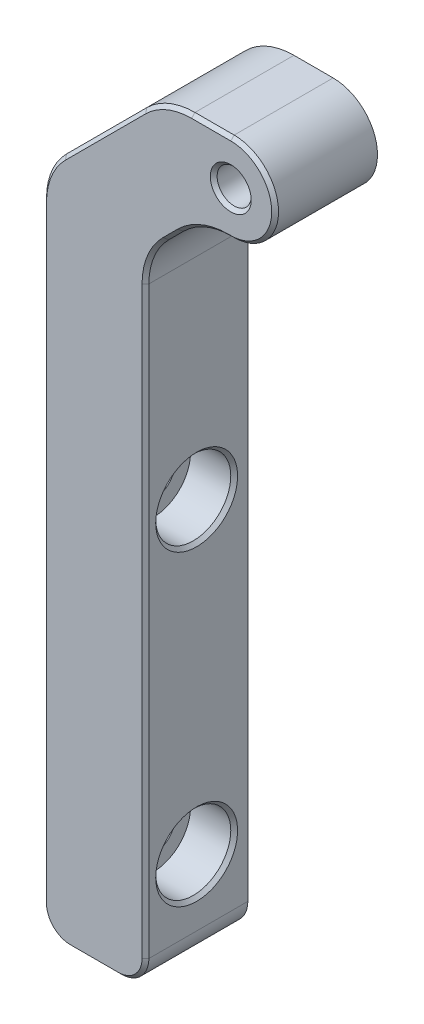
from build123d import *

# Parameters (mm, degrees)
BOSS_EXTRUDE1_DEPTH                                 = 15
TAP_DRILL_FOR_M6_TAP1_D                             = 5
CBORE_FOR_M6_HEX_SOCKET_HEAD_CAP_SCREW1_D           = 6.6
CBORE_FOR_M6_HEX_SOCKET_HEAD_CAP_SCREW1_CBORE_D     = 11
CBORE_FOR_M6_HEX_SOCKET_HEAD_CAP_SCREW1_CBORE_DEPTH = 6.4
CHAMFER1_SIZE                                       = 0.5


with BuildPart() as part:
    # Sketch1 → Boss-Extrude1 (new body)
    with BuildSketch(Plane.XY):
        with BuildLine():
            Line((2.914096072, -75.45920495), (9.914096072, -75.45920495))
            ThreePointArc((9.914096072, -75.45920495), (12.742523197, -74.287632074), (13.914096072, -71.45920495))
            Line((13.914096072, -71.45920495), (13.914096072, 14.148669163))
            ThreePointArc((13.914096072, 14.148669163), (14.675300747, 17.975503486), (16.84302826, 21.219736974))
            Line((16.84302826, 21.219736974), (18.985163884, 23.361872598))
            ThreePointArc((18.985163884, 23.361872598), (22.229397372, 25.529600111), (26.056231696, 26.290804786))
            Line((26.056231696, 26.290804786), (26.414096072, 26.290804786))
            ThreePointArc((26.414096072, 26.290804786), (32.914096072, 32.790804786), (26.414096072, 39.290804786))
            Line((26.414096072, 39.290804786), (20.671455385, 39.290804786))
            ThreePointArc((20.671455385, 39.290804786), (16.844621061, 38.529600111), (13.600387573, 36.361872598))
            Line((13.600387573, 36.361872598), (1.84302826, 24.604513285))
            ThreePointArc((1.84302826, 24.604513285), (-0.324699253, 21.360279797), (-1.085903928, 17.533445473))
            Line((-1.085903928, 17.533445473), (-1.085903928, -71.45920495))
            ThreePointArc((-1.085903928, -71.45920495), (0.085668947, -74.287632074), (2.914096072, -75.45920495))
        make_face()
    extrude(amount=BOSS_EXTRUDE1_DEPTH)

    # Tap Drill for M6 Tap1 (through all)
    with Locations(Plane.XY.offset(15)):
        with Locations((26.414096072, 32.790804786)):
            Hole(TAP_DRILL_FOR_M6_TAP1_D / 2)

    # CBORE for M6 Hex Socket Head Cap Screw1 (through all)
    with Locations(Plane(origin=(13.914096072, 0, 0), x_dir=(0, 0, -1), z_dir=(1, 0, 0))):
        with Locations((-7.5, -16.709195214), (-7.5, -61.709195214)):
            CounterBoreHole(CBORE_FOR_M6_HEX_SOCKET_HEAD_CAP_SCREW1_D / 2, CBORE_FOR_M6_HEX_SOCKET_HEAD_CAP_SCREW1_CBORE_D / 2, CBORE_FOR_M6_HEX_SOCKET_HEAD_CAP_SCREW1_CBORE_DEPTH)

    # Chamfer1
    chamfer1_edges = [part.edges().sort_by_distance(p)[0] for p in [
        (16.844621061, 38.529600111, 15),
        (7.721707916, 30.483192942, 15),
        (-0.324699253, 21.360279797, 15),
        (-1.085903928, -26.962879738, 15),
        (0.085668947, -74.287632074, 15),
        (6.414096072, -75.45920495, 15),
        (12.742523197, -74.287632074, 15),
        (13.914096072, -28.655267893, 15),
        (14.675300747, 17.975503486, 15),
        (17.914096072, 22.290804786, 15),
        (32.914096072, 32.790804786, 15),
        (22.229397372, 25.529600111, 15),
        (28.914096072, 32.790804786, 15),
        (26.235163884, 26.290804786, 15),
        (13.914096072, -61.709195214, 13),
        (13.914096072, -16.709195214, 13),
        (23.542775728, 39.290804786, 15),
    ]]
    chamfer(chamfer1_edges, length=CHAMFER1_SIZE)


solid = part.part
